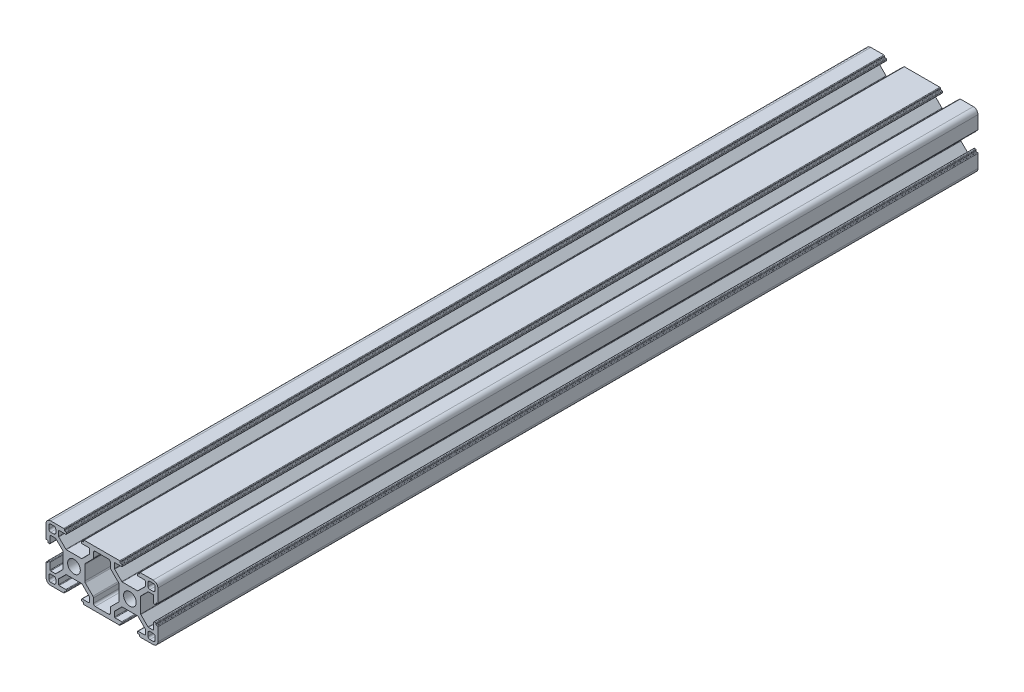
from build123d import *

# Parameters (mm, degrees)
MODEL_R         = 3.4
EXTRUDE_1_DEPTH = 440


with BuildPart() as part:
    # Model → 凸台-拉伸1 (new body)
    with BuildSketch(Plane.XY):
        with BuildLine():
            Line((147.993901934, 59.249179347), (148.493901934, 59.249179347))
            ThreePointArc((148.493901934, 59.249179347), (148.706033968, 59.337047312), (148.793901934, 59.549179347))
            Line((148.793901934, 59.549179347), (148.793901934, 59.949179347))
            ThreePointArc((148.793901934, 59.949179347), (148.881769899, 60.161311381), (149.093901934, 60.249179347))
            Line((149.093901934, 60.249179347), (156.093901934, 60.249179347))
            ThreePointArc((156.093901934, 60.249179347), (157.861668887, 59.5169463), (158.593901934, 57.749179346))
            Line((158.593901934, 57.749179346), (158.593901934, 50.749179347))
            ThreePointArc((158.593901934, 50.749179347), (158.506033968, 50.537047312), (158.293901934, 50.449179347))
            Line((158.293901934, 50.449179347), (157.893901934, 50.449179347))
            ThreePointArc((157.893901934, 50.449179347), (157.6817699, 50.361311381), (157.593901934, 50.149179347))
            Line((157.593901934, 50.149179347), (157.593901934, 49.649179347))
            ThreePointArc((157.593901934, 49.649179347), (157.506033968, 49.437047312), (157.293901934, 49.349179347))
            Line((157.293901934, 49.349179347), (156.693901934, 49.349179347))
            ThreePointArc((156.693901934, 49.349179347), (156.4817699, 49.437047312), (156.393901934, 49.649179347))
            Line((156.393901934, 49.649179347), (156.393901934, 53.199179347))
            ThreePointArc((156.393901934, 53.199179347), (156.306033968, 53.411311381), (156.093901934, 53.499179347))
            Line((156.093901934, 53.499179347), (153.523800921, 53.499179347))
            ThreePointArc((153.523800921, 53.499179347), (153.408995891, 53.476343206), (153.311668887, 53.411311381))
            Line((153.311668887, 53.411311381), (149.4817699, 49.581412394))
            ThreePointArc((149.4817699, 49.581412394), (149.416738074, 49.484085389), (149.393901934, 49.369280359))
            Line((149.393901934, 49.369280359), (149.393901934, 45.249179347))
            Line((149.393901934, 45.249179347), (149.393901934, 41.129078334))
            ThreePointArc((149.393901934, 41.129078334), (149.416738074, 41.014273304), (149.4817699, 40.9169463))
            Line((149.4817699, 40.9169463), (153.311668887, 37.087047312))
            ThreePointArc((153.311668887, 37.087047312), (153.408995891, 37.022015487), (153.523800921, 36.999179347))
            Line((153.523800921, 36.999179347), (156.093901934, 36.999179347))
            ThreePointArc((156.093901934, 36.999179347), (156.306033968, 37.087047312), (156.393901934, 37.299179347))
            Line((156.393901934, 37.299179347), (156.393901934, 40.849179347))
            ThreePointArc((156.393901934, 40.849179347), (156.4817699, 41.061311381), (156.693901934, 41.149179347))
            Line((156.693901934, 41.149179347), (157.293901934, 41.149179347))
            ThreePointArc((157.293901934, 41.149179347), (157.506033968, 41.061311381), (157.593901934, 40.849179347))
            Line((157.593901934, 40.849179347), (157.593901934, 40.349179347))
            ThreePointArc((157.593901934, 40.349179347), (157.6817699, 40.137047312), (157.893901934, 40.049179347))
            Line((157.893901934, 40.049179347), (158.293901934, 40.049179347))
            ThreePointArc((158.293901934, 40.049179347), (158.506033968, 39.961311381), (158.593901934, 39.749179347))
            Line((158.593901934, 39.749179347), (158.593901934, 32.749179347))
            ThreePointArc((158.593901934, 32.749179347), (157.861668887, 30.981412394), (156.093901934, 30.249179347))
            Line((156.093901934, 30.249179347), (149.093901934, 30.249179347))
            ThreePointArc((149.093901934, 30.249179347), (148.881769899, 30.337047312), (148.793901934, 30.549179346))
            Line((148.793901934, 30.549179346), (148.793901934, 30.949179346))
            ThreePointArc((148.793901934, 30.949179346), (148.706033968, 31.161311381), (148.493901934, 31.249179347))
            Line((148.493901934, 31.249179347), (147.993901934, 31.249179347))
            ThreePointArc((147.993901934, 31.249179347), (147.7817699, 31.337047312), (147.693901934, 31.549179347))
            Line((147.693901934, 31.549179347), (147.693901934, 32.149179347))
            ThreePointArc((147.693901934, 32.149179347), (147.7817699, 32.361311381), (147.993901934, 32.449179347))
            Line((147.993901934, 32.449179347), (151.543901934, 32.449179347))
            ThreePointArc((151.543901934, 32.449179347), (151.756033968, 32.537047312), (151.843901934, 32.749179347))
            Line((151.843901934, 32.749179347), (151.843901934, 35.319280359))
            ThreePointArc((151.843901934, 35.319280359), (151.821065794, 35.434085389), (151.756033968, 35.531412394))
            Line((151.756033968, 35.531412394), (147.926134981, 39.361311381))
            ThreePointArc((147.926134981, 39.361311381), (147.828807976, 39.426343206), (147.714002947, 39.449179347))
            Line((147.714002947, 39.449179347), (143.593901934, 39.449179347))
            Line((143.593901934, 39.449179347), (139.473800921, 39.449179347))
            ThreePointArc((139.473800921, 39.449179347), (139.358995892, 39.426343206), (139.261668887, 39.361311381))
            Line((139.261668887, 39.361311381), (135.4317699, 35.531412394))
            ThreePointArc((135.4317699, 35.531412394), (135.366738074, 35.434085389), (135.343901934, 35.319280359))
            Line((135.343901934, 35.319280359), (135.343901934, 32.749179347))
            ThreePointArc((135.343901934, 32.749179347), (135.4317699, 32.537047312), (135.643901934, 32.449179347))
            Line((135.643901934, 32.449179347), (139.193901934, 32.449179347))
            ThreePointArc((139.193901934, 32.449179347), (139.406033968, 32.361311381), (139.493901934, 32.149179347))
            Line((139.493901934, 32.149179347), (139.493901934, 31.549179347))
            ThreePointArc((139.493901934, 31.549179347), (139.406033968, 31.337047312), (139.193901934, 31.249179347))
            Line((139.193901934, 31.249179347), (138.693901934, 31.249179347))
            ThreePointArc((138.693901934, 31.249179347), (138.4817699, 31.161311381), (138.393901934, 30.949179346))
            Line((138.393901934, 30.949179346), (138.393901934, 30.549179347))
            ThreePointArc((138.393901934, 30.549179347), (138.306033968, 30.337047312), (138.093901934, 30.249179347))
            Line((138.093901934, 30.249179347), (119.093901934, 30.249179347))
            ThreePointArc((119.093901934, 30.249179347), (118.8817699, 30.337047312), (118.793901934, 30.549179347))
            Line((118.793901934, 30.549179347), (118.793901934, 30.949179346))
            ThreePointArc((118.793901934, 30.949179346), (118.706033968, 31.161311381), (118.493901934, 31.249179347))
            Line((118.493901934, 31.249179347), (117.993901934, 31.249179347))
            ThreePointArc((117.993901934, 31.249179347), (117.7817699, 31.337047312), (117.693901934, 31.549179347))
            Line((117.693901934, 31.549179347), (117.693901934, 32.149179347))
            ThreePointArc((117.693901934, 32.149179347), (117.7817699, 32.361311381), (117.993901934, 32.449179347))
            Line((117.993901934, 32.449179347), (121.543901934, 32.449179347))
            ThreePointArc((121.543901934, 32.449179347), (121.756033968, 32.537047312), (121.843901934, 32.749179347))
            Line((121.843901934, 32.749179347), (121.843901934, 35.319280359))
            ThreePointArc((121.843901934, 35.319280359), (121.821065794, 35.434085389), (121.756033968, 35.531412394))
            Line((121.756033968, 35.531412394), (117.926134981, 39.361311381))
            ThreePointArc((117.926134981, 39.361311381), (117.828807976, 39.426343206), (117.714002947, 39.449179347))
            Line((117.714002947, 39.449179347), (113.593901934, 39.449179347))
            Line((113.593901934, 39.449179347), (109.473800921, 39.449179347))
            ThreePointArc((109.473800921, 39.449179347), (109.358995892, 39.426343206), (109.261668887, 39.361311381))
            Line((109.261668887, 39.361311381), (105.4317699, 35.531412394))
            ThreePointArc((105.4317699, 35.531412394), (105.366738074, 35.434085389), (105.343901934, 35.319280359))
            Line((105.343901934, 35.319280359), (105.343901934, 32.749179347))
            ThreePointArc((105.343901934, 32.749179347), (105.4317699, 32.537047312), (105.643901934, 32.449179347))
            Line((105.643901934, 32.449179347), (109.193901934, 32.449179347))
            ThreePointArc((109.193901934, 32.449179347), (109.406033968, 32.361311381), (109.493901934, 32.149179347))
            Line((109.493901934, 32.149179347), (109.493901934, 31.549179347))
            ThreePointArc((109.493901934, 31.549179347), (109.406033968, 31.337047312), (109.193901934, 31.249179347))
            Line((109.193901934, 31.249179347), (108.693901934, 31.249179347))
            ThreePointArc((108.693901934, 31.249179347), (108.4817699, 31.161311381), (108.393901934, 30.949179346))
            Line((108.393901934, 30.949179346), (108.393901934, 30.549179346))
            ThreePointArc((108.393901934, 30.549179346), (108.306033968, 30.337047312), (108.093901934, 30.249179347))
            Line((108.093901934, 30.249179347), (101.093901934, 30.249179347))
            ThreePointArc((101.093901934, 30.249179347), (99.326134981, 30.981412394), (98.593901934, 32.749179347))
            Line((98.593901934, 32.749179347), (98.593901934, 39.749179347))
            ThreePointArc((98.593901934, 39.749179347), (98.6817699, 39.961311381), (98.893901934, 40.049179347))
            Line((98.893901934, 40.049179347), (99.293901934, 40.049179347))
            ThreePointArc((99.293901934, 40.049179347), (99.506033968, 40.137047312), (99.593901934, 40.349179347))
            Line((99.593901934, 40.349179347), (99.593901934, 40.849179347))
            ThreePointArc((99.593901934, 40.849179347), (99.6817699, 41.061311381), (99.893901934, 41.149179347))
            Line((99.893901934, 41.149179347), (100.493901934, 41.149179347))
            ThreePointArc((100.493901934, 41.149179347), (100.706033968, 41.061311381), (100.793901934, 40.849179347))
            Line((100.793901934, 40.849179347), (100.793901934, 37.299179347))
            ThreePointArc((100.793901934, 37.299179347), (100.8817699, 37.087047312), (101.093901934, 36.999179347))
            Line((101.093901934, 36.999179347), (103.664002947, 36.999179347))
            ThreePointArc((103.664002947, 36.999179347), (103.778807976, 37.022015487), (103.876134981, 37.087047312))
            Line((103.876134981, 37.087047312), (107.706033968, 40.9169463))
            ThreePointArc((107.706033968, 40.9169463), (107.771065794, 41.014273304), (107.793901934, 41.129078334))
            Line((107.793901934, 41.129078334), (107.793901934, 45.249179347))
            Line((107.793901934, 45.249179347), (107.793901934, 49.369280359))
            ThreePointArc((107.793901934, 49.369280359), (107.771065794, 49.484085389), (107.706033968, 49.581412394))
            Line((107.706033968, 49.581412394), (103.876134981, 53.411311381))
            ThreePointArc((103.876134981, 53.411311381), (103.778807976, 53.476343206), (103.664002947, 53.499179347))
            Line((103.664002947, 53.499179347), (101.093901934, 53.499179347))
            ThreePointArc((101.093901934, 53.499179347), (100.8817699, 53.411311381), (100.793901934, 53.199179347))
            Line((100.793901934, 53.199179347), (100.793901934, 49.649179347))
            ThreePointArc((100.793901934, 49.649179347), (100.706033968, 49.437047312), (100.493901934, 49.349179347))
            Line((100.493901934, 49.349179347), (99.893901934, 49.349179347))
            ThreePointArc((99.893901934, 49.349179347), (99.6817699, 49.437047312), (99.593901934, 49.649179347))
            Line((99.593901934, 49.649179347), (99.593901934, 50.149179347))
            ThreePointArc((99.593901934, 50.149179347), (99.506033968, 50.361311381), (99.293901934, 50.449179347))
            Line((99.293901934, 50.449179347), (98.893901934, 50.449179347))
            ThreePointArc((98.893901934, 50.449179347), (98.6817699, 50.537047312), (98.593901934, 50.749179347))
            Line((98.593901934, 50.749179347), (98.593901934, 57.749179346))
            ThreePointArc((98.593901934, 57.749179346), (99.326134981, 59.5169463), (101.093901934, 60.249179347))
            Line((101.093901934, 60.249179347), (108.093901934, 60.249179347))
            ThreePointArc((108.093901934, 60.249179347), (108.306033968, 60.161311381), (108.393901934, 59.949179347))
            Line((108.393901934, 59.949179347), (108.393901934, 59.549179347))
            ThreePointArc((108.393901934, 59.549179347), (108.4817699, 59.337047312), (108.693901934, 59.249179347))
            Line((108.693901934, 59.249179347), (109.193901934, 59.249179347))
            ThreePointArc((109.193901934, 59.249179347), (109.406033968, 59.161311381), (109.493901934, 58.949179347))
            Line((109.493901934, 58.949179347), (109.493901934, 58.349179347))
            ThreePointArc((109.493901934, 58.349179347), (109.406033968, 58.137047312), (109.193901934, 58.049179347))
            Line((109.193901934, 58.049179347), (105.643901934, 58.049179347))
            ThreePointArc((105.643901934, 58.049179347), (105.4317699, 57.961311381), (105.343901934, 57.749179347))
            Line((105.343901934, 57.749179347), (105.343901934, 55.179078334))
            ThreePointArc((105.343901934, 55.179078334), (105.366738074, 55.064273304), (105.4317699, 54.9669463))
            Line((105.4317699, 54.9669463), (109.261668887, 51.137047312))
            ThreePointArc((109.261668887, 51.137047312), (109.358995892, 51.072015487), (109.473800921, 51.049179347))
            Line((109.473800921, 51.049179347), (113.593901934, 51.049179347))
            Line((113.593901934, 51.049179347), (117.714002947, 51.049179347))
            ThreePointArc((117.714002947, 51.049179347), (117.828807976, 51.072015487), (117.926134981, 51.137047312))
            Line((117.926134981, 51.137047312), (121.756033968, 54.9669463))
            ThreePointArc((121.756033968, 54.9669463), (121.821065794, 55.064273304), (121.843901934, 55.179078334))
            Line((121.843901934, 55.179078334), (121.843901934, 57.749179347))
            ThreePointArc((121.843901934, 57.749179347), (121.756033968, 57.961311381), (121.543901934, 58.049179347))
            Line((121.543901934, 58.049179347), (117.993901934, 58.049179347))
            ThreePointArc((117.993901934, 58.049179347), (117.7817699, 58.137047312), (117.693901934, 58.349179347))
            Line((117.693901934, 58.349179347), (117.693901934, 58.949179347))
            ThreePointArc((117.693901934, 58.949179347), (117.7817699, 59.161311381), (117.993901934, 59.249179347))
            Line((117.993901934, 59.249179347), (118.493901934, 59.249179347))
            ThreePointArc((118.493901934, 59.249179347), (118.706033968, 59.337047312), (118.793901934, 59.549179347))
            Line((118.793901934, 59.549179347), (118.793901934, 59.949179347))
            ThreePointArc((118.793901934, 59.949179347), (118.881769899, 60.161311381), (119.093901934, 60.249179347))
            Line((119.093901934, 60.249179347), (138.093901934, 60.249179347))
            ThreePointArc((138.093901934, 60.249179347), (138.306033968, 60.161311381), (138.393901934, 59.949179347))
            Line((138.393901934, 59.949179347), (138.393901934, 59.549179347))
            ThreePointArc((138.393901934, 59.549179347), (138.4817699, 59.337047312), (138.693901934, 59.249179347))
            Line((138.693901934, 59.249179347), (139.193901934, 59.249179347))
            ThreePointArc((139.193901934, 59.249179347), (139.406033968, 59.161311381), (139.493901934, 58.949179347))
            Line((139.493901934, 58.949179347), (139.493901934, 58.349179347))
            ThreePointArc((139.493901934, 58.349179347), (139.406033968, 58.137047312), (139.193901934, 58.049179347))
            Line((139.193901934, 58.049179347), (135.643901934, 58.049179347))
            ThreePointArc((135.643901934, 58.049179347), (135.4317699, 57.961311381), (135.343901934, 57.749179347))
            Line((135.343901934, 57.749179347), (135.343901934, 55.179078334))
            ThreePointArc((135.343901934, 55.179078334), (135.366738074, 55.064273304), (135.4317699, 54.9669463))
            Line((135.4317699, 54.9669463), (139.261668887, 51.137047312))
            ThreePointArc((139.261668887, 51.137047312), (139.358995892, 51.072015487), (139.473800921, 51.049179347))
            Line((139.473800921, 51.049179347), (143.593901934, 51.049179347))
            Line((143.593901934, 51.049179347), (147.714002947, 51.049179347))
            ThreePointArc((147.714002947, 51.049179347), (147.828807976, 51.072015487), (147.926134981, 51.137047312))
            Line((147.926134981, 51.137047312), (151.756033968, 54.9669463))
            ThreePointArc((151.756033968, 54.9669463), (151.821065794, 55.064273304), (151.843901934, 55.179078334))
            Line((151.843901934, 55.179078334), (151.843901934, 57.749179347))
            ThreePointArc((151.843901934, 57.749179347), (151.756033968, 57.961311381), (151.543901934, 58.049179347))
            Line((151.543901934, 58.049179347), (147.993901934, 58.049179347))
            ThreePointArc((147.993901934, 58.049179347), (147.7817699, 58.137047312), (147.693901934, 58.349179347))
            Line((147.693901934, 58.349179347), (147.693901934, 58.949179347))
            ThreePointArc((147.693901934, 58.949179347), (147.7817699, 59.161311381), (147.993901934, 59.249179347))
        make_face()
        with Locations((113.593901934, 45.249179347)):
            Circle(MODEL_R, mode=Mode.SUBTRACT)
        with Locations((143.593901934, 45.249179347)):
            Circle(MODEL_R, mode=Mode.SUBTRACT)
        with BuildLine():
            Line((154.343901934, 58.749179347), (156.093901934, 58.749179347))
            ThreePointArc((156.093901934, 58.749179347), (156.801008715, 58.456286128), (157.093901934, 57.749179347))
            Line((157.093901934, 57.749179347), (157.093901934, 55.999179347))
            ThreePointArc((157.093901934, 55.999179347), (156.801008715, 55.292072565), (156.093901934, 54.999179347))
            Line((156.093901934, 54.999179347), (154.343901934, 54.999179347))
            ThreePointArc((154.343901934, 54.999179347), (153.636795153, 55.292072565), (153.343901934, 55.999179347))
            Line((153.343901934, 55.999179347), (153.343901934, 57.749179347))
            ThreePointArc((153.343901934, 57.749179347), (153.636795153, 58.456286128), (154.343901934, 58.749179347))
        make_face(mode=Mode.SUBTRACT)
        with BuildLine():
            Line((102.843901934, 58.749179347), (101.093901934, 58.749179347))
            ThreePointArc((101.093901934, 58.749179347), (100.386795153, 58.456286128), (100.093901934, 57.749179347))
            Line((100.093901934, 57.749179347), (100.093901934, 55.999179347))
            ThreePointArc((100.093901934, 55.999179347), (100.386795153, 55.292072565), (101.093901934, 54.999179347))
            Line((101.093901934, 54.999179347), (102.843901934, 54.999179347))
            ThreePointArc((102.843901934, 54.999179347), (103.551008715, 55.292072565), (103.843901934, 55.999179347))
            Line((103.843901934, 55.999179347), (103.843901934, 57.749179347))
            ThreePointArc((103.843901934, 57.749179347), (103.551008715, 58.456286128), (102.843901934, 58.749179347))
        make_face(mode=Mode.SUBTRACT)
        with BuildLine():
            Line((154.343901934, 31.749179347), (156.093901934, 31.749179347))
            ThreePointArc((156.093901934, 31.749179347), (156.801008715, 32.042072565), (157.093901934, 32.749179347))
            Line((157.093901934, 32.749179347), (157.093901934, 34.499179347))
            ThreePointArc((157.093901934, 34.499179347), (156.801008715, 35.206286128), (156.093901934, 35.499179347))
            Line((156.093901934, 35.499179347), (154.343901934, 35.499179347))
            ThreePointArc((154.343901934, 35.499179347), (153.636795153, 35.206286128), (153.343901934, 34.499179347))
            Line((153.343901934, 34.499179347), (153.343901934, 32.749179347))
            ThreePointArc((153.343901934, 32.749179347), (153.636795153, 32.042072565), (154.343901934, 31.749179347))
        make_face(mode=Mode.SUBTRACT)
        with BuildLine():
            Line((119.393901934, 49.079330866), (119.393901934, 45.249179347))
            Line((119.393901934, 45.249179347), (119.393901934, 41.419027828))
            ThreePointArc((119.393901934, 41.419027828), (119.470022401, 41.036344395), (119.686795153, 40.711921046))
            Line((119.686795153, 40.711921046), (123.751008715, 36.647707484))
            ThreePointArc((123.751008715, 36.647707484), (123.967781466, 36.323284135), (124.043901934, 35.940600703))
            Line((124.043901934, 35.940600703), (124.043901934, 33.449179347))
            ThreePointArc((124.043901934, 33.449179347), (124.336795153, 32.742072565), (125.043901934, 32.449179347))
            Line((125.043901934, 32.449179347), (128.593901934, 32.449179347))
            Line((128.593901934, 32.449179347), (132.143901934, 32.449179347))
            ThreePointArc((132.143901934, 32.449179347), (132.851008715, 32.742072565), (133.143901934, 33.449179347))
            Line((133.143901934, 33.449179347), (133.143901934, 35.940600703))
            ThreePointArc((133.143901934, 35.940600703), (133.220022401, 36.323284135), (133.436795153, 36.647707484))
            Line((133.436795153, 36.647707484), (137.501008715, 40.711921046))
            ThreePointArc((137.501008715, 40.711921046), (137.717781466, 41.036344395), (137.793901934, 41.419027828))
            Line((137.793901934, 41.419027828), (137.793901934, 45.249179347))
            Line((137.793901934, 45.249179347), (137.793901934, 49.079330866))
            ThreePointArc((137.793901934, 49.079330866), (137.717781466, 49.462014298), (137.501008715, 49.786437647))
            Line((137.501008715, 49.786437647), (133.436795153, 53.850651209))
            ThreePointArc((133.436795153, 53.850651209), (133.220022401, 54.175074558), (133.143901934, 54.55775799))
            Line((133.143901934, 54.55775799), (133.143901934, 57.049179347))
            ThreePointArc((133.143901934, 57.049179347), (132.851008715, 57.756286128), (132.143901934, 58.049179347))
            Line((132.143901934, 58.049179347), (128.593901934, 58.049179347))
            Line((128.593901934, 58.049179347), (125.043901934, 58.049179347))
            ThreePointArc((125.043901934, 58.049179347), (124.336795153, 57.756286128), (124.043901934, 57.049179347))
            Line((124.043901934, 57.049179347), (124.043901934, 54.55775799))
            ThreePointArc((124.043901934, 54.55775799), (123.967781466, 54.175074558), (123.751008715, 53.850651209))
            Line((123.751008715, 53.850651209), (119.686795153, 49.786437647))
            ThreePointArc((119.686795153, 49.786437647), (119.470022401, 49.462014298), (119.393901934, 49.079330866))
        make_face(mode=Mode.SUBTRACT)
        with BuildLine():
            Line((102.843901934, 31.749179347), (101.093901934, 31.749179347))
            ThreePointArc((101.093901934, 31.749179347), (100.386795153, 32.042072565), (100.093901934, 32.749179347))
            Line((100.093901934, 32.749179347), (100.093901934, 34.499179347))
            ThreePointArc((100.093901934, 34.499179347), (100.386795153, 35.206286128), (101.093901934, 35.499179347))
            Line((101.093901934, 35.499179347), (102.843901934, 35.499179347))
            ThreePointArc((102.843901934, 35.499179347), (103.551008715, 35.206286128), (103.843901934, 34.499179347))
            Line((103.843901934, 34.499179347), (103.843901934, 32.749179347))
            ThreePointArc((103.843901934, 32.749179347), (103.551008715, 32.042072565), (102.843901934, 31.749179347))
        make_face(mode=Mode.SUBTRACT)
    extrude(amount=EXTRUDE_1_DEPTH)


solid = part.part
